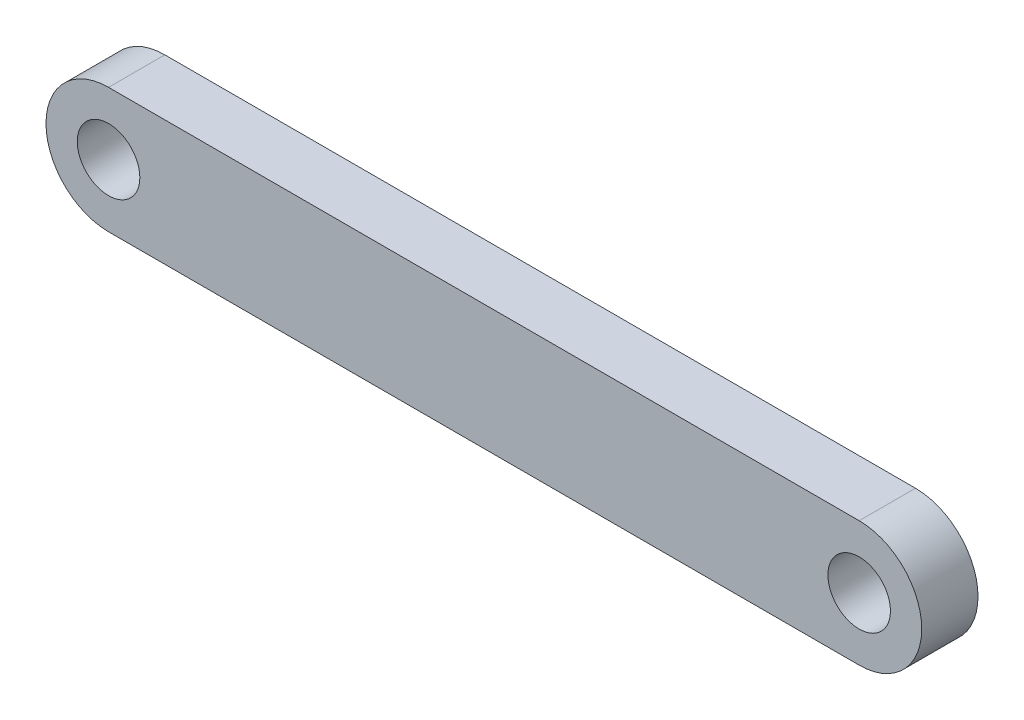
from build123d import *

# Parameters (mm, degrees)
SKETCH1_R           = 5
BOSS_EXTRUDE1_DEPTH = 4.5


with BuildPart() as part:
    # Sketch1 → Boss-Extrude1 (new, symmetric)
    with BuildSketch(Plane.XY):
        with BuildLine():
            Line((-60, 10), (60, 10))
            ThreePointArc((60, 10), (70, 0), (60, -10))
            Line((60, -10), (-60, -10))
            ThreePointArc((-60, -10), (-70, 0), (-60, 10))
        make_face()
        with Locations((-60, 0)):
            Circle(SKETCH1_R, mode=Mode.SUBTRACT)
        with Locations((60, 0)):
            Circle(SKETCH1_R, mode=Mode.SUBTRACT)
    extrude(amount=BOSS_EXTRUDE1_DEPTH, both=True)


solid = part.part
